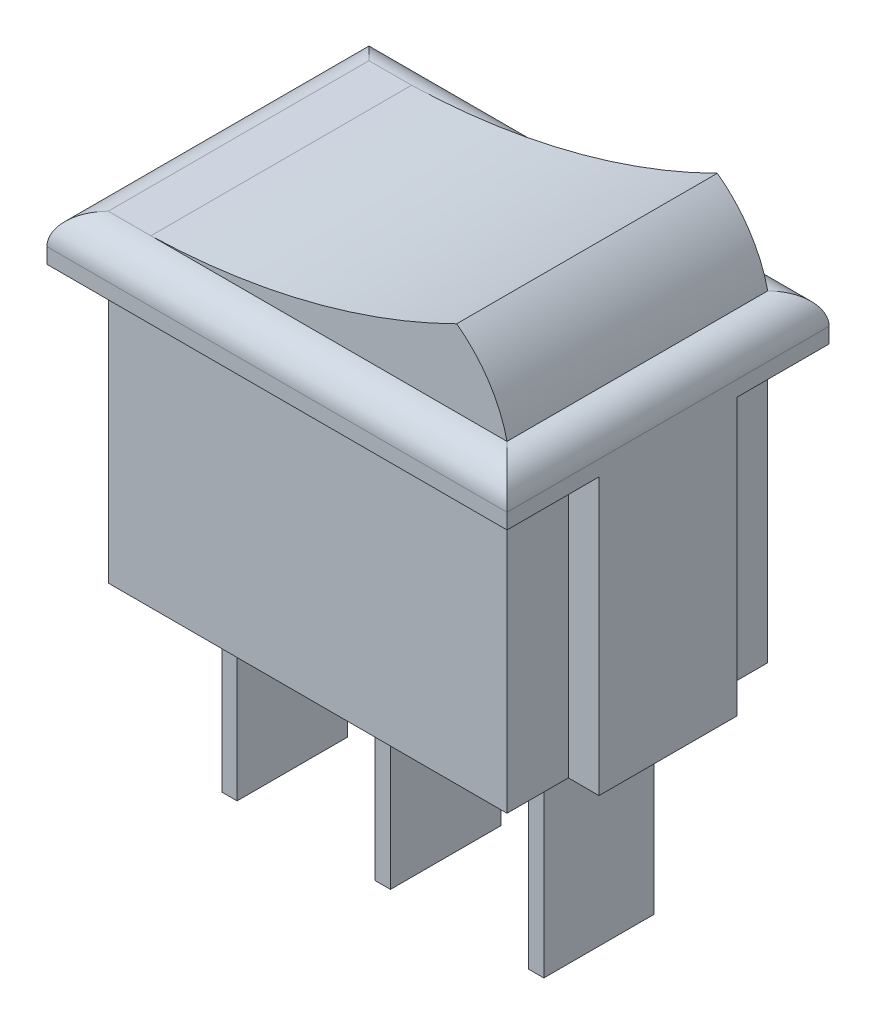
from build123d import *

# Parameters (mm, degrees)
ESQUISSE1_W        = 13
ESQUISSE1_H        = 8.5
ESQUISSE1_W_2      = 1
ESQUISSE1_H_2      = 4.5
BOSS_EXTRU_1_DEPTH = 9
ESQUISSE2_W        = 15
ESQUISSE2_H        = 10.5
BOSS_EXTRU_2_DEPTH = 1.5
CONG_1_R           = 1
ESQUISSE3_W        = 0.5
ESQUISSE3_H        = 3.6
BOSS_EXTRU_3_DEPTH = 6.5
BOSS_EXTRU_4_DEPTH = 8.5


with BuildPart() as part:
    # Esquisse1 → Boss.-Extru.1 (new body)
    with BuildSketch(Plane(origin=(0, 0, 0), x_dir=(1, 0, 0), z_dir=(0, 1, 0))):
        with Locations((6.5, 4.25)):
            Rectangle(ESQUISSE1_W, ESQUISSE1_H)
        with Locations((-0.5, 4.25)):
            Rectangle(ESQUISSE1_W_2, ESQUISSE1_H_2)
        with Locations((13.5, 4.25)):
            Rectangle(ESQUISSE1_W_2, ESQUISSE1_H_2)
    extrude(amount=BOSS_EXTRU_1_DEPTH)

    # Esquisse2 → Boss.-Extru.2 (add)
    with BuildSketch(Plane(origin=(0, 9, 0), x_dir=(1, 0, 0), z_dir=(0, 1, 0))):
        with Locations((6.5, 4.25)):
            Rectangle(ESQUISSE2_W, ESQUISSE2_H)
    extrude(amount=BOSS_EXTRU_2_DEPTH)

    # Congé1
    cong_1_edges = [part.edges().sort_by_distance(p)[0] for p in [
        (-1, 10.5, -4.25),
        (6.5, 10.5, 1),
        (14, 10.5, -4.25),
        (6.5, 10.5, -9.5),
    ]]
    fillet(cong_1_edges, radius=CONG_1_R)

    # Esquisse3 → Boss.-Extru.3 (add)
    with BuildSketch(Plane.XZ):
        with Locations((6.5, -4.25)):
            Rectangle(ESQUISSE3_W, ESQUISSE3_H)
        with Locations((1.5, -4.25)):
            Rectangle(ESQUISSE3_W, ESQUISSE3_H)
        with Locations((11.5, -4.25)):
            Rectangle(ESQUISSE3_W, ESQUISSE3_H)
    extrude(amount=BOSS_EXTRU_3_DEPTH)

    # Esquisse4 → Boss.-Extru.4 (add)
    with BuildSketch(Plane(origin=(0, 0, -8.5), x_dir=(-1, 0, 0), z_dir=(0, 0, -1))):
        with BuildLine():
            ThreePointArc((-11.358192951, 13), (-12.404531, 11.898047996), (-13, 10.5))
            Line((-13, 10.5), (-4.652568423, 10.5))
            Line((-4.652568423, 10.5), (-1.388259271, 10.5))
            ThreePointArc((-1.388259271, 10.5), (-3.07180416, 10.608445517), (-4.743510251, 10.835343224))
            ThreePointArc((-4.743510251, 10.835343224), (-8.130042008, 11.675684327), (-11.358192951, 13))
        make_face()
    extrude(amount=-BOSS_EXTRU_4_DEPTH)


solid = part.part
